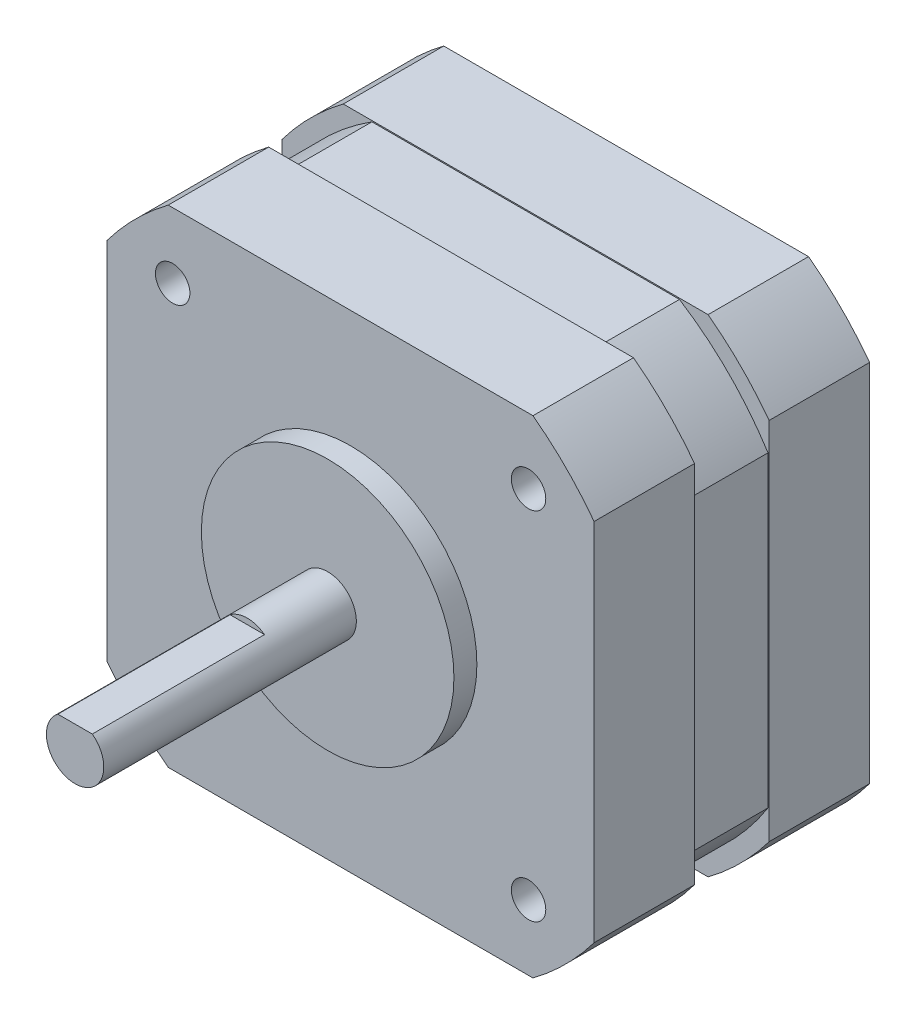
from build123d import *

# Parameters (mm, degrees)
SKETCH1_R                       = 2.5
BOSS_EXTRUDE1_DEPTH             = 24
SKETCH2_R                       = 11
BOSS_EXTRUDE2_DEPTH             = 2
SKETCH3_W                       = 42.418
SKETCH3_H                       = 42.418
BOSS_EXTRUDE3_DEPTH             = 24
CUT_EXTRUDE1_DEPTH              = 49
M3X0_5_TAPPED_HOLE1_D           = 2.5
M3X0_5_TAPPED_HOLE1_DEPTH       = 7.5
M3X0_5_TAPPED_HOLE1_CBORE_D     = 3
M3X0_5_TAPPED_HOLE1_CBORE_DEPTH = 6
M3X0_5_TAPPED_HOLE1_TIP         = 0.751075774
CUT_EXTRUDE2_DEPTH              = 15
CUT_EXTRUDE3_DEPTH              = 3.25
CUT_EXTRUDE3_DEPTH_BACK         = 3.25


with BuildPart() as part:
    # Sketch1 → Boss-Extrude1 (new body)
    with BuildSketch(Plane.XY):
        Circle(SKETCH1_R)
    extrude(amount=BOSS_EXTRUDE1_DEPTH)

    # Sketch2 → Boss-Extrude2 (add)
    with BuildSketch(Plane(origin=(0, 0, 0), x_dir=(-1, 0, 0), z_dir=(0, 0, -1))):
        Circle(SKETCH2_R)
    extrude(amount=-BOSS_EXTRUDE2_DEPTH)

    # Sketch3 → Boss-Extrude3 (add)
    with BuildSketch(Plane(origin=(0, 0, 0), x_dir=(-1, 0, 0), z_dir=(0, 0, -1))):
        Rectangle(SKETCH3_W, SKETCH3_H)
    extrude(amount=BOSS_EXTRUDE3_DEPTH)

    # Sketch4 → Cut-Extrude1 (cut, through all)
    with BuildSketch(Plane(origin=(0, 0, -24), x_dir=(-1, 0, 0), z_dir=(0, 0, -1))):
        with BuildLine():
            Line((-21.209, -15.887992919), (-21.209, -21.209))
            Line((-21.209, -21.209), (-15.887992919, -21.209))
            ThreePointArc((-15.887992919, -21.209), (-18.738329701, -18.738329701), (-21.209, -15.887992919))
        make_face()
        with BuildLine():
            Line((15.887992919, -21.209), (21.209, -21.209))
            Line((21.209, -21.209), (21.209, -15.887992919))
            ThreePointArc((21.209, -15.887992919), (18.738329701, -18.738329701), (15.887992919, -21.209))
        make_face()
        with BuildLine():
            Line((21.209, 15.887992919), (21.209, 21.209))
            Line((21.209, 21.209), (15.887992919, 21.209))
            ThreePointArc((15.887992919, 21.209), (18.738329701, 18.738329701), (21.209, 15.887992919))
        make_face()
        with BuildLine():
            Line((-15.887992919, 21.209), (-21.209, 21.209))
            Line((-21.209, 21.209), (-21.209, 15.887992919))
            ThreePointArc((-21.209, 15.887992919), (-18.738329701, 18.738329701), (-15.887992919, 21.209))
        make_face()
    extrude(amount=-CUT_EXTRUDE1_DEPTH, mode=Mode.SUBTRACT)

    # M3x0.5 Tapped Hole1
    with Locations(Plane.XY):
        with Locations((-15.5, 15.5), (-15.5, -15.5), (15.5, -15.5), (15.5, 15.5)):
            CounterBoreHole(M3X0_5_TAPPED_HOLE1_D / 2, M3X0_5_TAPPED_HOLE1_CBORE_D / 2, M3X0_5_TAPPED_HOLE1_CBORE_DEPTH, depth=M3X0_5_TAPPED_HOLE1_DEPTH)
            with Locations((0, 0, -(M3X0_5_TAPPED_HOLE1_DEPTH + M3X0_5_TAPPED_HOLE1_TIP / 2))):  # 118° drill point
                Cone(0, M3X0_5_TAPPED_HOLE1_D / 2, M3X0_5_TAPPED_HOLE1_TIP, mode=Mode.SUBTRACT)

    # Sketch7 → Cut-Extrude2 (cut)
    with BuildSketch(Plane.XY.offset(24)):
        with BuildLine():
            Line((-1.5, 2), (1.5, 2))
            ThreePointArc((1.5, 2), (0, 2.5), (-1.5, 2))
        make_face()
    extrude(amount=-CUT_EXTRUDE2_DEPTH, mode=Mode.SUBTRACT)

    # Sketch8 → Cut-Extrude3 (cut, two sides)
    with BuildSketch(Plane.XY.offset(-12)) as cut_extrude3_sk:
        with BuildLine():
            Line((15.887992919, 21.209), (-15.887992919, 21.209))
            ThreePointArc((-15.887992919, 21.209), (-18.738329701, 18.738329701), (-21.209, 15.887992919))
            Line((-21.209, 15.887992919), (-21.209, -15.887992919))
            ThreePointArc((-21.209, -15.887992919), (-18.738329701, -18.738329701), (-15.887992919, -21.209))
            Line((-15.887992919, -21.209), (15.887992919, -21.209))
            ThreePointArc((15.887992919, -21.209), (18.738329701, -18.738329701), (21.209, -15.887992919))
            Line((21.209, -15.887992919), (21.209, 15.887992919))
            ThreePointArc((21.209, 15.887992919), (18.738329701, 18.738329701), (15.887992919, 21.209))
        make_face()
        with BuildLine():
            Line((-13.394406258, 21.109), (13.394406258, 21.109))
            ThreePointArc((13.394406258, 21.109), (17.67766953, 17.67766953), (21.109, 13.394406258))
            Line((21.109, 13.394406258), (21.109, -13.394406258))
            ThreePointArc((21.109, -13.394406258), (17.67766953, -17.67766953), (13.394406258, -21.109))
            Line((13.394406258, -21.109), (-13.394406258, -21.109))
            ThreePointArc((-13.394406258, -21.109), (-17.67766953, -17.67766953), (-21.109, -13.394406258))
            Line((-21.109, -13.394406258), (-21.109, 13.394406258))
            ThreePointArc((-21.109, 13.394406258), (-17.67766953, 17.67766953), (-13.394406258, 21.109))
        make_face(mode=Mode.SUBTRACT)
    extrude(amount=CUT_EXTRUDE3_DEPTH, mode=Mode.SUBTRACT)
    extrude(cut_extrude3_sk.sketch, amount=-CUT_EXTRUDE3_DEPTH_BACK, mode=Mode.SUBTRACT)


solid = part.part
